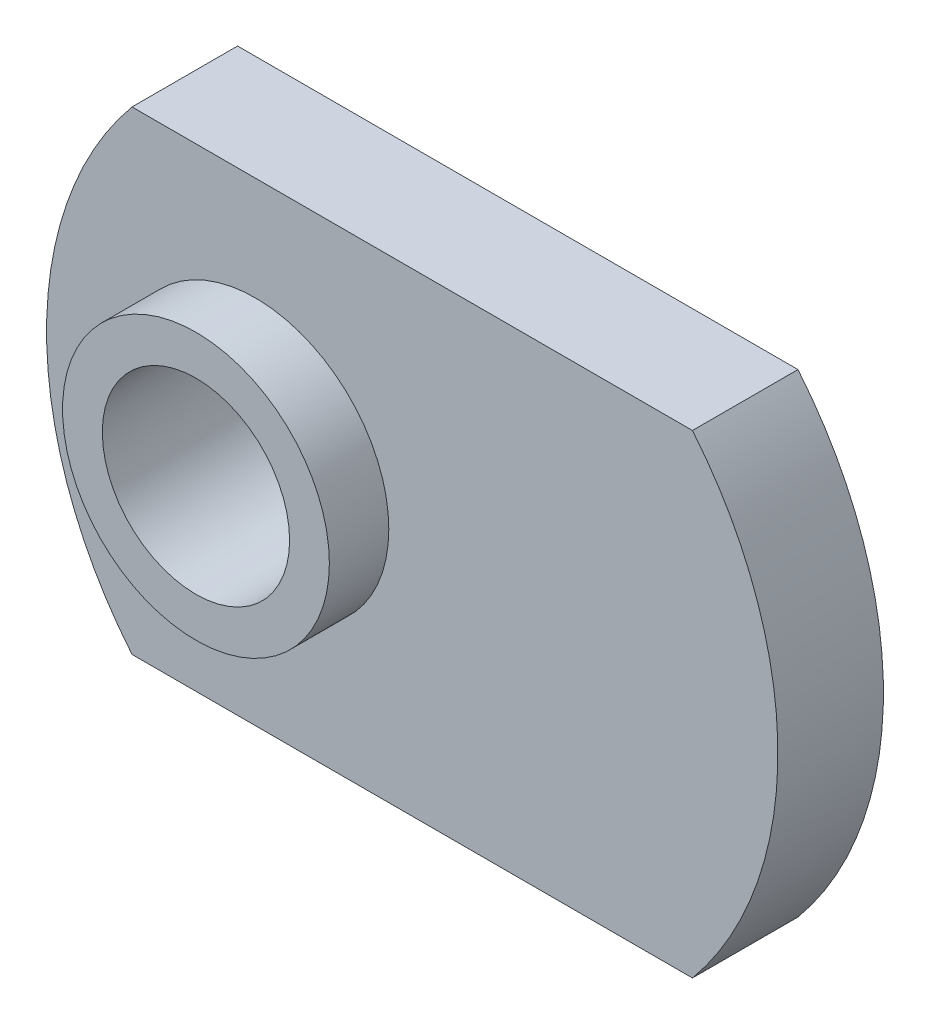
from build123d import *

# Parameters (mm, degrees)
BOSS_EXTRUDE1_DEPTH = 3.6068
SKETCH2_W           = 4.5593
SKETCH2_H           = 2.032
HOLE1_D             = 6.4008
HOLE1_DEPTH         = 5.6388


with BuildPart() as part:
    # Sketch1 → Boss-Extrude1 (new body)
    with BuildSketch(Plane.XY.offset(1.8034)):
        with BuildLine():
            Line((9.576261807, 8.1026), (-9.576261807, 8.1026))
            ThreePointArc((-9.576261807, 8.1026), (-12.4968, 0), (-9.576261807, -8.1026))
            Line((-9.576261807, -8.1026), (9.576261807, -8.1026))
            ThreePointArc((9.576261807, -8.1026), (12.4968, 0), (9.576261807, 8.1026))
        make_face()
    extrude(amount=-BOSS_EXTRUDE1_DEPTH)

    # Sketch2 → Revolve1 (revolve)
    with BuildSketch(Plane(origin=(0, 0, 0), x_dir=(1, 0, 0), z_dir=(0, 1, 0))):
        with Locations((-3.07975, -2.8194)):
            Rectangle(SKETCH2_W, SKETCH2_H)
    revolve(axis=Axis((-5.3594, 0, 1.8034), (0, 0, 1)))

    # Hole1
    with Locations(Plane(origin=(0, 0, -1.8034), x_dir=(-1, 0, 0), z_dir=(0, 0, -1))):
        with Locations((5.3594, 0)):
            Hole(HOLE1_D / 2, depth=HOLE1_DEPTH)


solid = part.part
